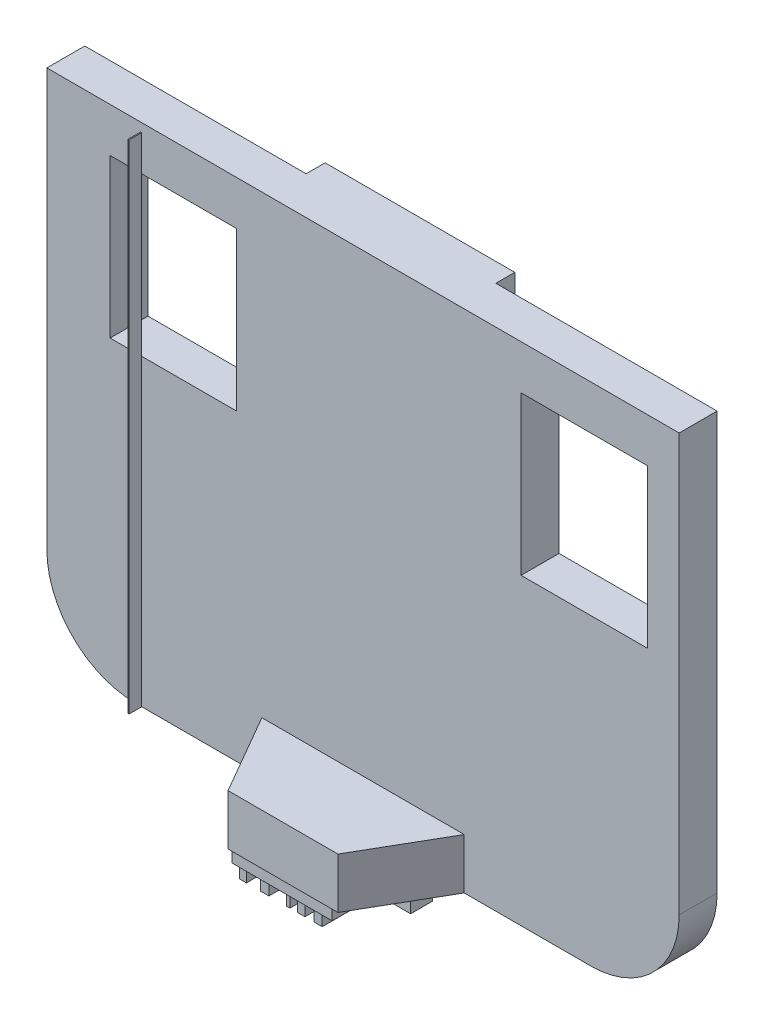
from build123d import *

# Parameters (mm, degrees)
SKETCH1_W           = 127
SKETCH1_H           = 101.6
BOSS_EXTRUDE1_DEPTH = 7.62
SKETCH3_W           = 38.1
SKETCH3_H           = 101.6
BOSS_EXTRUDE2_DEPTH = 3.81
SKETCH4_W           = 25.4
SKETCH4_H           = 31.75
CUT_EXTRUDE1_DEPTH  = 7.62
FILLET1_R           = 17.78
BOSS_EXTRUDE3_DEPTH = 10.16
SKETCH6_W           = 1.401774382
SKETCH6_H           = 7.084034581
SKETCH6_W_2         = 1.657965541
SKETCH6_W_3         = 0.723515752
SKETCH6_W_4         = 1.5072414
SKETCH6_W_5         = 1.65796554
SKETCH6_W_6         = 12.660827761
SKETCH6_H_2         = 4.394326049
SKETCH6_W_7         = 12.660827762
BOSS_EXTRUDE4_DEPTH = 5.08
SKETCH7_W           = 0.989162869
SKETCH7_H           = 4.394326049
SKETCH7_W_2         = 1.219468424
CUT_EXTRUDE2_DEPTH  = 5.08
SKETCH8_W           = 20.126718604
SKETCH8_H           = 7.896323228
BOSS_EXTRUDE5_DEPTH = 2.54
SKETCH9_W           = 0.213588314
SKETCH9_H           = 99.880159493
BOSS_EXTRUDE6_DEPTH = 2.54


with BuildPart() as part:
    # Sketch1 → Boss-Extrude1 (new body)
    with BuildSketch(Plane.XY):
        with Locations((63.5, 50.8)):
            Rectangle(SKETCH1_W, SKETCH1_H)
    extrude(amount=BOSS_EXTRUDE1_DEPTH)

    # Sketch3 → Boss-Extrude2 (add)
    with BuildSketch(Plane(origin=(0, 0, 0), x_dir=(-1, 0, 0), z_dir=(0, 0, -1))):
        with Locations((-63.5, 50.8)):
            Rectangle(SKETCH3_W, SKETCH3_H)
    extrude(amount=BOSS_EXTRUDE2_DEPTH)

    # Sketch4 → Cut-Extrude1 (cut)
    with BuildSketch(Plane(origin=(0, 0, 0), x_dir=(-1, 0, 0), z_dir=(0, 0, -1))):
        with Locations((-25.4, 76.835)):
            Rectangle(SKETCH4_W, SKETCH4_H)
        with Locations((-107.95, 76.835)):
            Rectangle(SKETCH4_W, SKETCH4_H)
    extrude(amount=-CUT_EXTRUDE1_DEPTH, mode=Mode.SUBTRACT)

    # Fillet1
    fillet1_edges = [part.edges().sort_by_distance(p)[0] for p in [
        (127, 0, 3.81),
        (0, 0, 3.81),
    ]]
    fillet(fillet1_edges, radius=FILLET1_R)

    # Sketch5 → Boss-Extrude3 (add)
    with BuildSketch(Plane.XZ):
        Polygon((43.18, 7.62), (52.463035847, 23.698689735), (74.536964153, 23.698689735), (83.82, 7.62), align=None)
    extrude(amount=-BOSS_EXTRUDE3_DEPTH)

    # Sketch6 → Boss-Extrude4 (add)
    with BuildSketch(Plane.XZ):
        with Locations((54.433923038, 19.138517409)):
            Rectangle(SKETCH6_W, SKETCH6_H)
        with Locations((58.82755166, 19.138517409)):
            Rectangle(SKETCH6_W_2, SKETCH6_H)
        with Locations((63.515052474, 19.138517409)):
            Rectangle(SKETCH6_W_3, SKETCH6_H)
        with Locations((66.13767245, 19.138517409)):
            Rectangle(SKETCH6_W_4, SKETCH6_H)
        with Locations((69.528965601, 19.138517409)):
            Rectangle(SKETCH6_W_5, SKETCH6_H)
        with Locations((57.99856889, 9.353111302)):
            Rectangle(SKETCH6_W_6, SKETCH6_H_2)
        with Locations((70.659396651, 9.353111302)):
            Rectangle(SKETCH6_W_7, SKETCH6_H_2)
    extrude(amount=BOSS_EXTRUDE4_DEPTH)

    # Sketch7 → Cut-Extrude2 (cut)
    with BuildSketch(Plane.XZ.offset(5.08)):
        with Locations((63.834401336, 9.353111302)):
            Rectangle(SKETCH7_W, SKETCH7_H)
        with Locations((64.938716982, 9.353111302)):
            Rectangle(SKETCH7_W_2, SKETCH7_H)
    extrude(amount=-CUT_EXTRUDE2_DEPTH, mode=Mode.SUBTRACT)

    # Sketch8 → Boss-Extrude5 (add)
    with BuildSketch(Plane.XZ):
        with Locations((62.814636368, 19.241529297)):
            Rectangle(SKETCH8_W, SKETCH8_H)
    extrude(amount=BOSS_EXTRUDE5_DEPTH)

    # Sketch9 → Boss-Extrude6 (add)
    with BuildSketch(Plane.XY.offset(7.62)):
        with Locations((18.943205843, 49.940079747)):
            Rectangle(SKETCH9_W, SKETCH9_H)
    extrude(amount=BOSS_EXTRUDE6_DEPTH)


solid = part.part
